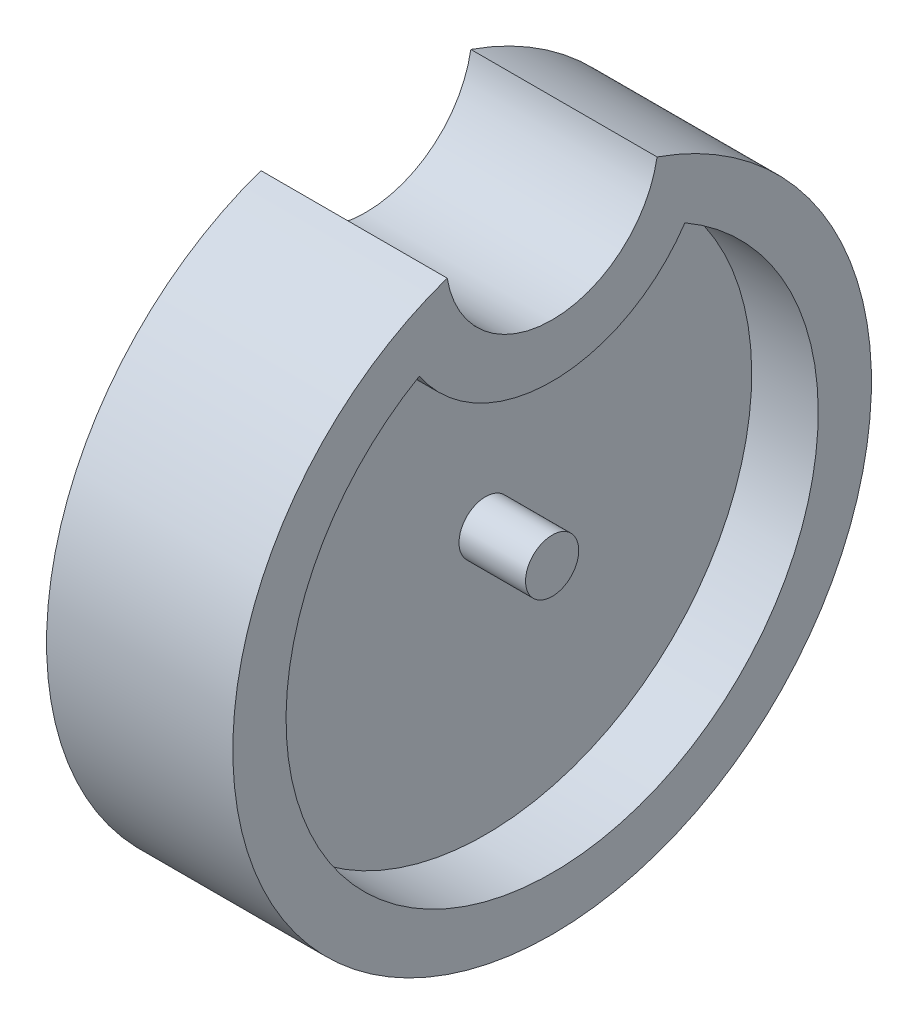
from build123d import *

# Parameters (mm, degrees)
BOSS_EXTRUDE1_DEPTH = 5.55625
BOSS_EXTRUDE2_DEPTH = 1.5875
SKETCH6_R           = 1.5875
BOSS_EXTRUDE3_DEPTH = 5.55625


with BuildPart() as part:
    # Sketch1 → Boss-Extrude1 (new body, symmetric)
    with BuildSketch(Plane(origin=(0, 0, 0), x_dir=(0, 0, -1), z_dir=(1, 0, 0))):
        with BuildLine():
            ThreePointArc((-6.261184437, 17.991666667), (0, -19.05), (6.261184437, 17.991666667))
            ThreePointArc((6.261184437, 17.991666667), (0, 12.7), (-6.261184437, 17.991666667))
        make_face()
        with BuildLine():
            ThreePointArc((-7.919841469, 13.758333333), (0, 9.525), (7.919841469, 13.758333333))
            ThreePointArc((7.919841469, 13.758333333), (0, -15.875), (-7.919841469, 13.758333333))
        make_face(mode=Mode.SUBTRACT)
    extrude(amount=BOSS_EXTRUDE1_DEPTH, both=True)

    # Sketch3 → Boss-Extrude2 (add, symmetric)
    with BuildSketch(Plane(origin=(0, 0, 0), x_dir=(0, 0, -1), z_dir=(1, 0, 0))):
        with BuildLine():
            ThreePointArc((-7.919841469, 13.758333333), (0, -15.875), (7.919841469, 13.758333333))
            ThreePointArc((7.919841469, 13.758333333), (0, 9.525), (-7.919841469, 13.758333333))
        make_face()
    extrude(amount=BOSS_EXTRUDE2_DEPTH, both=True)

    # Sketch6 → Boss-Extrude3 (add, symmetric)
    with BuildSketch(Plane(origin=(0, 0, 0), x_dir=(0, 0, -1), z_dir=(1, 0, 0))):
        Circle(SKETCH6_R)
    extrude(amount=BOSS_EXTRUDE3_DEPTH, both=True)


solid = part.part
